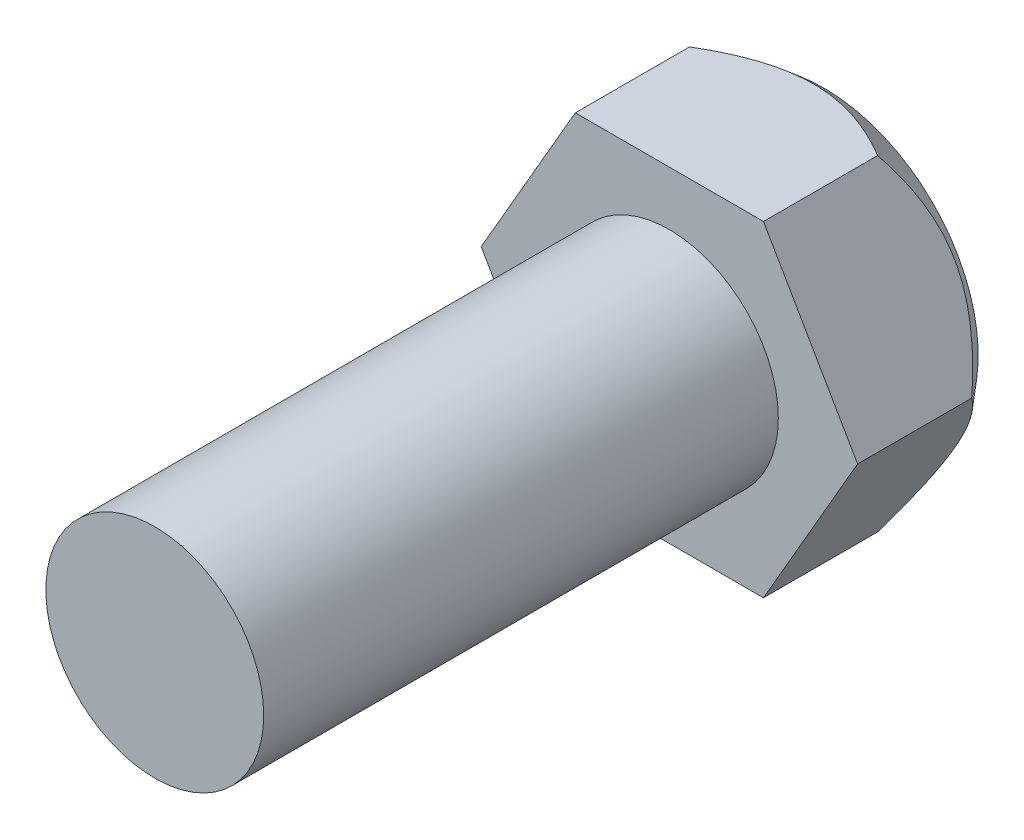
from build123d import *

# Parameters (mm, degrees)
SALIENTE_EXTRUIR1_DEPTH = 9
CROQUIS2_R              = 6.35
SALIENTE_EXTRUIR2_DEPTH = 30
CROQUIS3_R              = 18.81463578
CROQUIS3_R_2            = 9
CORTAR_EXTRUIR1_DEPTH   = 10
CORTAR_EXTRUIR1_TAPER   = 40


with BuildPart() as part:
    # Croquis1 → Saliente-Extruir1 (new body)
    with BuildSketch(Plane.XY):
        Polygon((10.969655115, 0), (5.484827557, 9.5), (-5.484827557, 9.5), (-10.969655115, 0), (-5.484827557, -9.5), (5.484827557, -9.5), align=None)
    extrude(amount=SALIENTE_EXTRUIR1_DEPTH)

    # Croquis2 → Saliente-Extruir2 (add)
    with BuildSketch(Plane.XY.offset(9)):
        Circle(CROQUIS2_R)
    extrude(amount=SALIENTE_EXTRUIR2_DEPTH)

    # Croquis3 → Cortar-Extruir1 (cut)
    with BuildSketch(Plane(origin=(0, 0, 0), x_dir=(-1, 0, 0), z_dir=(0, 0, -1))):
        Circle(CROQUIS3_R)
        Circle(CROQUIS3_R_2, mode=Mode.SUBTRACT)
    extrude(amount=-CORTAR_EXTRUIR1_DEPTH, taper=CORTAR_EXTRUIR1_TAPER, mode=Mode.SUBTRACT)


solid = part.part
